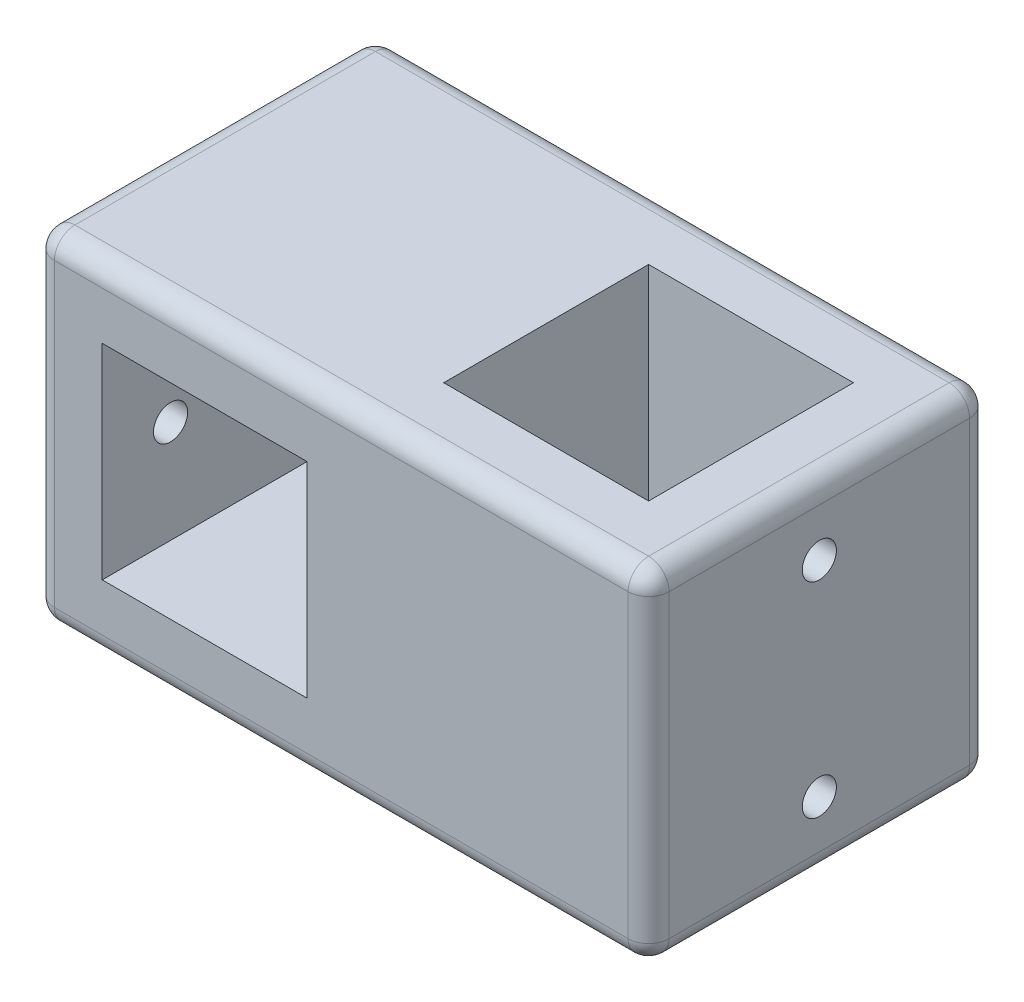
from build123d import *

# Parameters (mm, degrees)
SKETCH1_W           = 90
SKETCH1_H           = 50
BOSS_EXTRUDE1_DEPTH = 50
CUT_EXTRUDE1_REACH  = 52
SKETCH2_W           = 30
SKETCH2_H           = 30
CUT_EXTRUDE2_REACH  = 52
SKETCH3_W           = 30
SKETCH3_H           = 30
FILLET1_R           = 3
CUT_EXTRUDE3_REACH  = 92
SKETCH4_R           = 2.5
CUT_EXTRUDE4_REACH  = 92
SKETCH5_R           = 2.5


with BuildPart() as part:
    # Sketch1 → Boss-Extrude1 (new body)
    with BuildSketch(Plane.XY):
        Rectangle(SKETCH1_W, SKETCH1_H)
    extrude(amount=BOSS_EXTRUDE1_DEPTH)

    # Sketch2 → Cut-Extrude1 (cut, up to next)
    with BuildSketch(Plane.XY.offset(50), mode=Mode.PRIVATE) as cut_extrude1_sk1:
        with Locations((-20, 0)):
            Rectangle(SKETCH2_W, SKETCH2_H)
    cut_extrude1_tool1 = extrude(cut_extrude1_sk1.sketch, amount=-CUT_EXTRUDE1_REACH, mode=Mode.PRIVATE) & part.part
    add(cut_extrude1_tool1.solids().sort_by_distance((-20, 0, 50))[0], mode=Mode.SUBTRACT)

    # Sketch3 → Cut-Extrude2 (cut, up to next)
    with BuildSketch(Plane(origin=(0, 25, 0), x_dir=(1, 0, 0), z_dir=(0, 1, 0)), mode=Mode.PRIVATE) as cut_extrude2_sk1:
        with Locations((20, -25)):
            Rectangle(SKETCH3_W, SKETCH3_H)
    cut_extrude2_tool1 = extrude(cut_extrude2_sk1.sketch, amount=-CUT_EXTRUDE2_REACH, mode=Mode.PRIVATE) & part.part
    add(cut_extrude2_tool1.solids().sort_by_distance((20, 25, 25))[0], mode=Mode.SUBTRACT)

    # Fillet1
    fillet1_edges = [part.edges().sort_by_distance(p)[0] for p in [
        (45, 0, 50),
        (0, 25, 50),
        (-45, 0, 50),
        (0, 25, 0),
        (45, 0, 0),
        (0, -25, 0),
        (-45, 0, 0),
        (-45, 25, 25),
        (45, 25, 25),
        (45, -25, 25),
        (-45, -25, 25),
        (0, -25, 50),
    ]]
    fillet(fillet1_edges, radius=FILLET1_R)

    # Sketch4 → Cut-Extrude3 (cut, up to next)
    with BuildSketch(Plane.ZY.offset(45), mode=Mode.PRIVATE) as cut_extrude3_sk1:
        with Locations((10, 0)):
            Circle(SKETCH4_R)
    cut_extrude3_tool1 = extrude(cut_extrude3_sk1.sketch, amount=-CUT_EXTRUDE3_REACH, mode=Mode.PRIVATE) & part.part
    add(cut_extrude3_tool1.solids().sort_by_distance((-45, 0, 10))[0], mode=Mode.SUBTRACT)
    # Sketch4 → Cut-Extrude3 (cut, up to next)
    with BuildSketch(Plane.ZY.offset(45), mode=Mode.PRIVATE) as cut_extrude3_sk2:
        with Locations((40, 0)):
            Circle(SKETCH4_R)
    cut_extrude3_tool2 = extrude(cut_extrude3_sk2.sketch, amount=-CUT_EXTRUDE3_REACH, mode=Mode.PRIVATE) & part.part
    add(cut_extrude3_tool2.solids().sort_by_distance((-45, 0, 40))[0], mode=Mode.SUBTRACT)

    # Sketch5 → Cut-Extrude4 (cut, up to next)
    with BuildSketch(Plane(origin=(45, 0, 0), x_dir=(0, 0, -1), z_dir=(1, 0, 0)), mode=Mode.PRIVATE) as cut_extrude4_sk1:
        with Locations((-25, 15)):
            Circle(SKETCH5_R)
    cut_extrude4_tool1 = extrude(cut_extrude4_sk1.sketch, amount=-CUT_EXTRUDE4_REACH, mode=Mode.PRIVATE) & part.part
    add(cut_extrude4_tool1.solids().sort_by_distance((45, 15, 25))[0], mode=Mode.SUBTRACT)
    # Sketch5 → Cut-Extrude4 (cut, up to next)
    with BuildSketch(Plane(origin=(45, 0, 0), x_dir=(0, 0, -1), z_dir=(1, 0, 0)), mode=Mode.PRIVATE) as cut_extrude4_sk2:
        with Locations((-25, -15)):
            Circle(SKETCH5_R)
    cut_extrude4_tool2 = extrude(cut_extrude4_sk2.sketch, amount=-CUT_EXTRUDE4_REACH, mode=Mode.PRIVATE) & part.part
    add(cut_extrude4_tool2.solids().sort_by_distance((45, -15, 25))[0], mode=Mode.SUBTRACT)


solid = part.part
